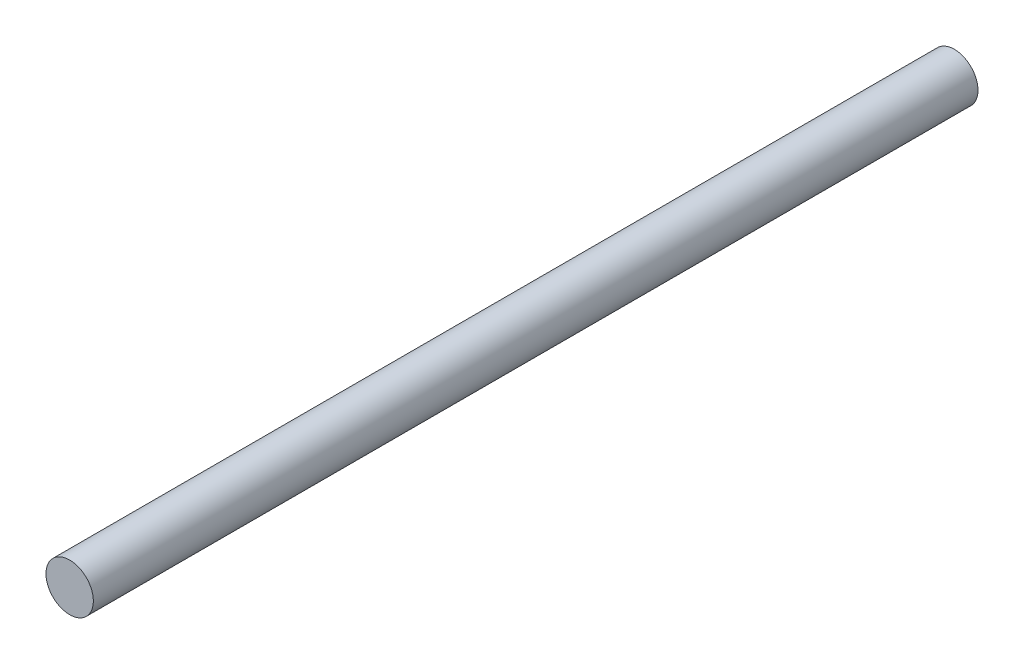
from build123d import *

# Parameters (mm, degrees)
SKETCH1_R           = 15
BOSS_EXTRUDE1_DEPTH = 560


with BuildPart() as part:
    # Sketch1 → Boss-Extrude1 (new body)
    with BuildSketch(Plane.XY):
        Circle(SKETCH1_R)
    extrude(amount=BOSS_EXTRUDE1_DEPTH)


solid = part.part
